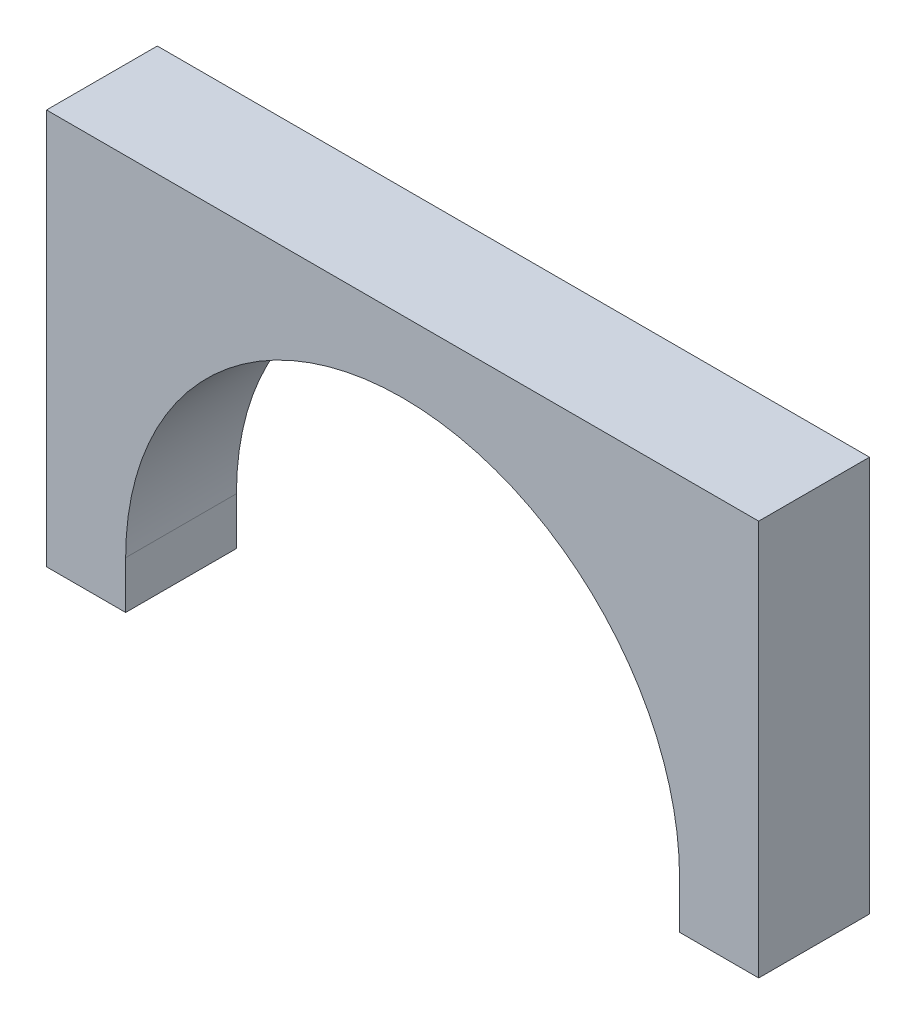
from build123d import *

# Parameters (mm, degrees)
BOSS_EXTRUDE1_DEPTH = 7


with BuildPart() as part:
    # Sketch1 → Boss-Extrude1 (new body)
    with BuildSketch(Plane.XY):
        with BuildLine():
            Line((22.5, 0), (17.5, 0))
            Line((17.5, 0), (17.5, 3))
            ThreePointArc((17.5, 3), (0, 20.5), (-17.5, 3))
            Line((-17.5, 3), (-17.5, 0))
            Line((-17.5, 0), (-22.5, 0))
            Line((-22.5, 0), (-22.5, 25))
            Line((-22.5, 25), (22.5, 25))
            Line((22.5, 25), (22.5, 0))
        make_face()
    extrude(amount=BOSS_EXTRUDE1_DEPTH)


solid = part.part
